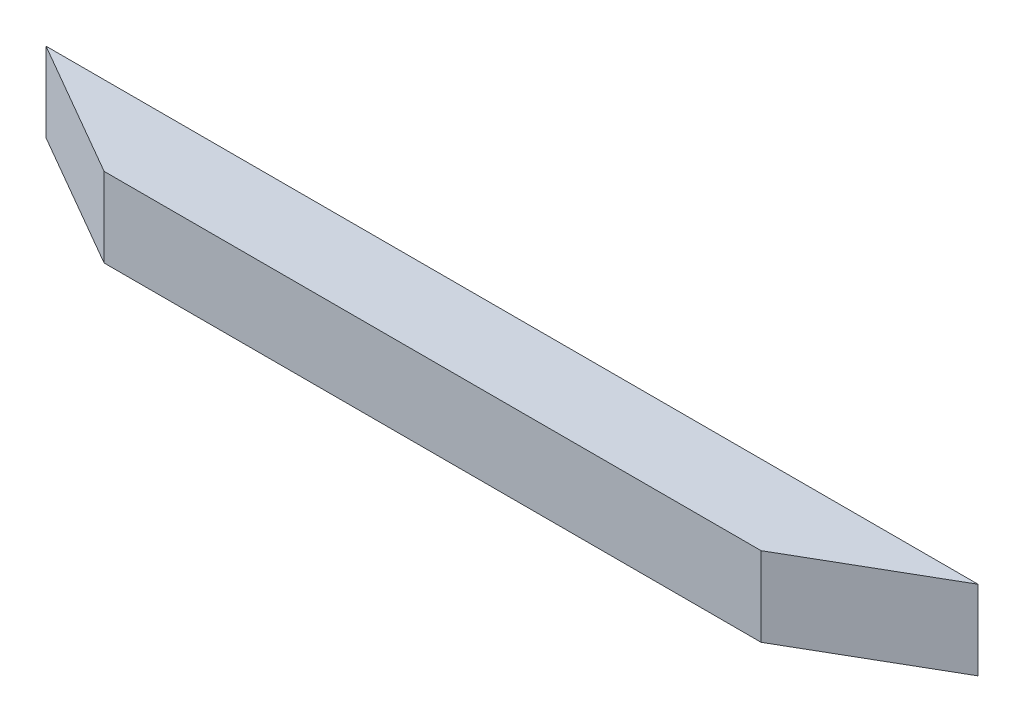
from build123d import *

# Parameters (mm, degrees)
BOSS_EXTRUDE1_DEPTH = 20


with BuildPart() as part:
    # Sketch1 → Boss-Extrude1 (new body)
    with BuildSketch(Plane(origin=(0, 0, 0), x_dir=(1, 0, 0), z_dir=(0, 1, 0))):
        Polygon((-82.759491924, -10), (82.759491924, -10), (117.400508076, 10), (-117.400508076, 10), align=None)
    extrude(amount=BOSS_EXTRUDE1_DEPTH)


solid = part.part
